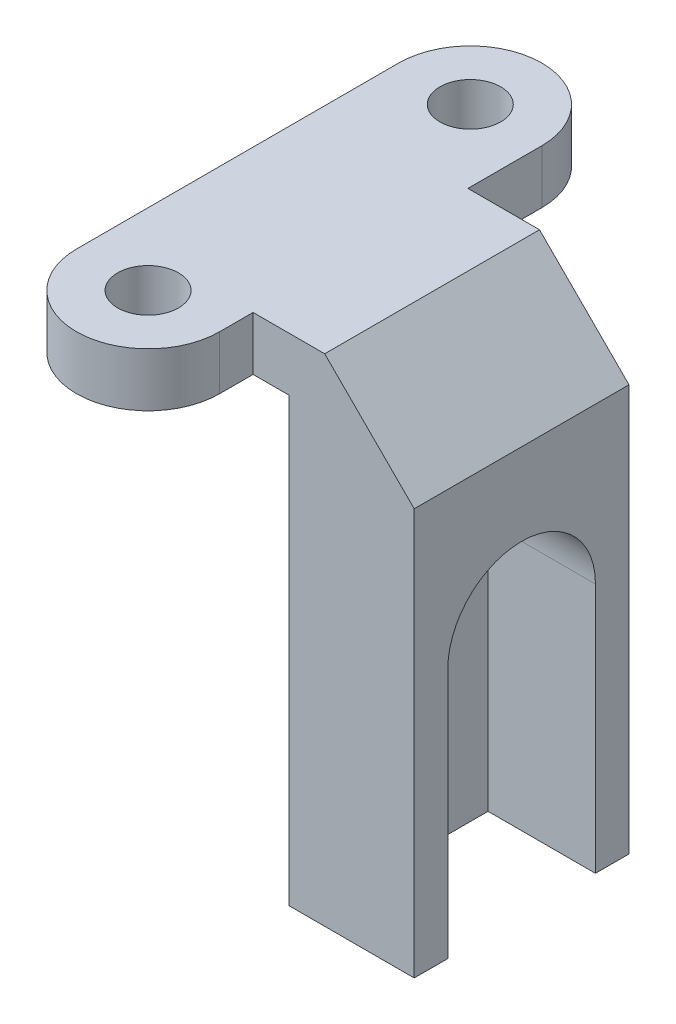
from build123d import *

# Parameters (mm, degrees)
BOSS_EXTRUDE1_DEPTH      = 3
M3_CLEARANCE_HOLE1_D     = 3.4
M3_CLEARANCE_HOLE1_DEPTH = 10
M3_CLEARANCE_HOLE1_TIP   = 1.021463052
SKETCH2_W                = 7
SKETCH2_H                = 12
BOSS_EXTRUDE2_DEPTH      = 24.7
CUT_EXTRUDE1_DEPTH       = 6
CHAMFER3_SIZE            = 5


with BuildPart() as part:
    # Sketch1 → Boss-Extrude1 (new body)
    with BuildSketch(Plane(origin=(0, 0, 0), x_dir=(1, 0, 0), z_dir=(0, 1, 0))):
        with BuildLine():
            ThreePointArc((-4, -9), (0, -13), (4, -9))
            Line((4, -9), (4, -7.132441433))
            Line((4, -7.132441433), (13, -7.132441433))
            Line((13, -7.132441433), (13, 4.867558567))
            Line((13, 4.867558567), (4, 4.867558567))
            Line((4, 4.867558567), (4, 9))
            ThreePointArc((4, 9), (0, 13), (-4, 9))
            Line((-4, 9), (-4, 4.867558567))
            Line((-4, 4.867558567), (-4, -9))
        make_face()
    extrude(amount=BOSS_EXTRUDE1_DEPTH)

    # M3 Clearance Hole1
    with Locations(Plane(origin=(0, 3, 0), x_dir=(1, 0, 0), z_dir=(0, 1, 0))):
        with Locations((0, -9), (0, 9)):
            Hole(M3_CLEARANCE_HOLE1_D / 2, depth=M3_CLEARANCE_HOLE1_DEPTH)
            with Locations((0, 0, -(M3_CLEARANCE_HOLE1_DEPTH + M3_CLEARANCE_HOLE1_TIP / 2))):  # 118° drill point
                Cone(0, M3_CLEARANCE_HOLE1_D / 2, M3_CLEARANCE_HOLE1_TIP, mode=Mode.SUBTRACT)

    # Sketch2 → Boss-Extrude2 (add)
    with BuildSketch(Plane.XZ):
        with Locations((9.5, 1.132441433)):
            Rectangle(SKETCH2_W, SKETCH2_H)
    extrude(amount=BOSS_EXTRUDE2_DEPTH)

    # Sketch3 → Cut-Extrude1 (cut)
    with BuildSketch(Plane(origin=(13, 0, 0), x_dir=(0, 0, -1), z_dir=(1, 0, 0))):
        with BuildLine():
            Line((2.992558567, -24.7), (-5.257441433, -24.7))
            Line((-5.257441433, -24.7), (-5.257441433, -10.7))
            ThreePointArc((-5.257441433, -10.7), (-1.132441433, -6.575), (2.992558567, -10.7))
            Line((2.992558567, -10.7), (2.992558567, -24.7))
        make_face()
    extrude(amount=-CUT_EXTRUDE1_DEPTH, mode=Mode.SUBTRACT)

    # Chamfer3
    chamfer3_edges = [part.edges().sort_by_distance(p)[0] for p in [
        (13, 3, 1.132441433),
    ]]
    chamfer(chamfer3_edges, length=CHAMFER3_SIZE)


solid = part.part
